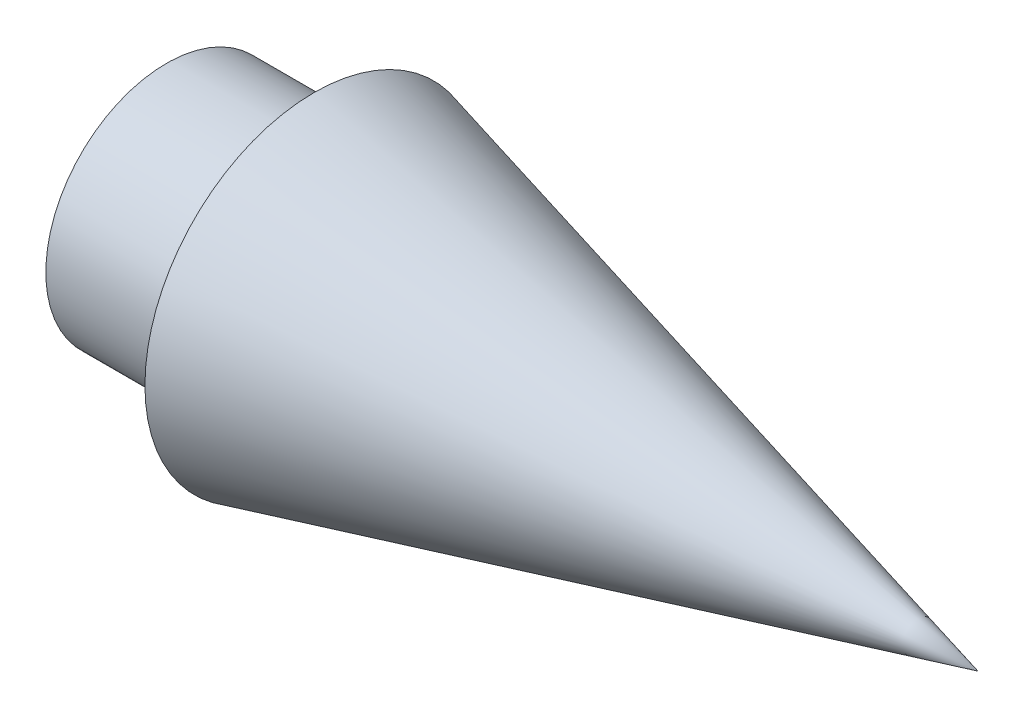
from build123d import *

# Parameters (mm, degrees)
F_1_4_20_TAPPED_HOLE1_D     = 5.1054
F_1_4_20_TAPPED_HOLE1_DEPTH = 19.05
F_1_4_20_TAPPED_HOLE1_TIP   = 1.533816902


with BuildPart() as part:
    # Sketch1 → Revolve1 (revolve)
    with BuildSketch(Plane(origin=(0, 0, 0), x_dir=(1, 0, 0), z_dir=(0, 1, 0))):
        Polygon((0, 10.3886), (0, 14.557883), (57.15, 0), (0, 0), (-12.7, 0), (-12.7, 10.3886), align=None)
    revolve(axis=Axis((57.15, 0, 0), (-1, 0, 0)))

    # 1/4-20 Tapped Hole1
    with Locations(Plane.ZY.offset(12.7)):
        with Locations((0, 0)):
            Hole(F_1_4_20_TAPPED_HOLE1_D / 2, depth=F_1_4_20_TAPPED_HOLE1_DEPTH)
            with Locations((0, 0, -(F_1_4_20_TAPPED_HOLE1_DEPTH + F_1_4_20_TAPPED_HOLE1_TIP / 2))):  # 118° drill point
                Cone(0, F_1_4_20_TAPPED_HOLE1_D / 2, F_1_4_20_TAPPED_HOLE1_TIP, mode=Mode.SUBTRACT)


solid = part.part
